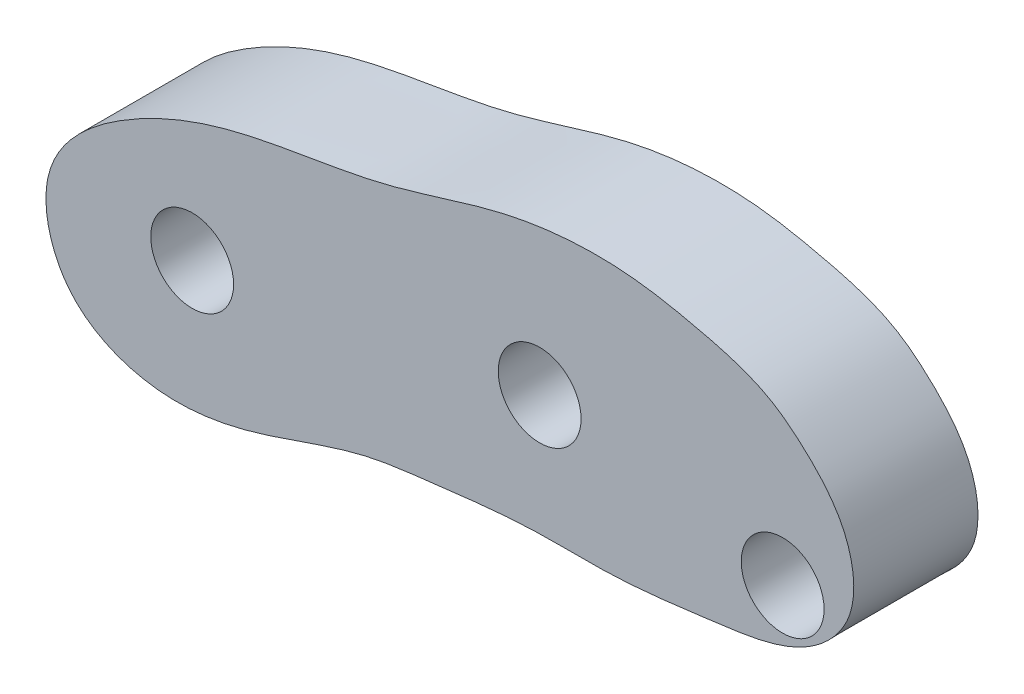
from build123d import *

# Parameters (mm, degrees)
SKETCH1_R           = 1
BOSS_EXTRUDE1_DEPTH = 3


with BuildPart() as part:
    # Sketch1 → Boss-Extrude1 (new body)
    with BuildSketch(Plane.XY):
        with BuildLine():
            add(Edge.make_bspline(
                [(-17.074740123, 10.546209688), (-16.869791791, 11.4951904), (-15.18903758, 12.884194545), (-12.311639203, 13.965336301), (-9.112696586, 14.273637066), (-5.988092391, 15.467215488), (-3.364120851, 15.645267824), (-1.208813654, 15.199242508), (0.193260384, 14.828884468), (1.365266095, 13.871913892), (2.316668382, 12.808353966), (2.526841308, 11.050790683), (1.151885174, 9.561039335), (-1.026470169, 9.297830917), (-3.278337639, 8.986780597), (-5.557941854, 9.075951408), (-7.511444078, 8.822651501), (-9.823926079, 8.568495952), (-11.983434709, 7.60726753), (-14.550886302, 7.220084903), (-16.811031378, 8.199080092), (-17.226445219, 9.843763325), (-17.074740123, 10.546209688)],
                knots=[0, 0, 0, 0, 0.064734106, 0.125809223, 0.207281305, 0.274075056, 0.347051232, 0.376812323, 0.420550282, 0.440494447, 0.476416642, 0.513364336, 0.54518357, 0.599503304, 0.653127591, 0.697205558, 0.749778401, 0.783749038, 0.850663978, 0.905143138, 0.952083075, 1, 1, 1, 1], degree=3))
        make_face()
        with Locations((-13.593083041, 10.546209688)):
            Circle(SKETCH1_R, mode=Mode.SUBTRACT)
        with Locations((0.664508579, 10.883300461)):
            Circle(SKETCH1_R, mode=Mode.SUBTRACT)
        with Locations((-5.203033993, 11.928629148)):
            Circle(SKETCH1_R, mode=Mode.SUBTRACT)
    extrude(amount=BOSS_EXTRUDE1_DEPTH)


solid = part.part
